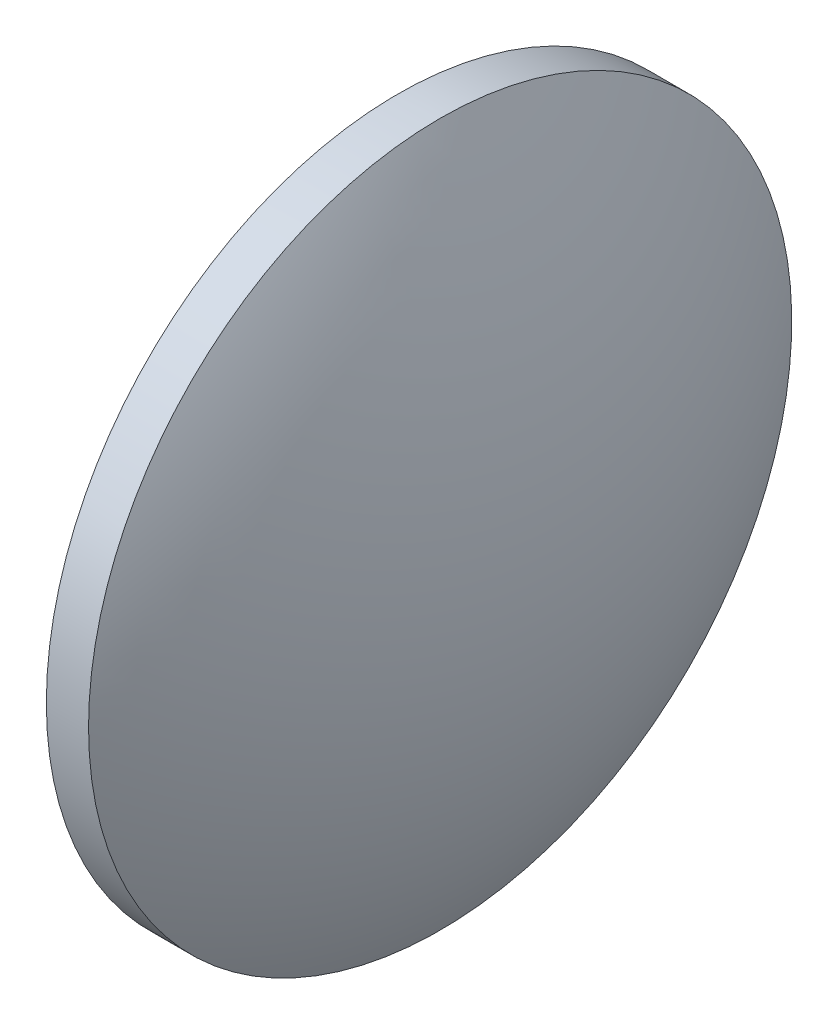
from build123d import *


with BuildPart() as part:
    # 草图1 → 旋转1 (revolve)
    with BuildSketch(Plane.XY):
        with BuildLine():
            Line((343.284470129, 9.632589186), (343.284470129, 34.632589186))
            Line((343.284470129, 34.632589186), (346.284470129, 34.632589186))
            ThreePointArc((346.284470129, 34.632589186), (351.095994088, 22.541912367), (352.734470129, 9.632589186))
            Line((352.734470129, 9.632589186), (343.284470129, 9.632589186))
        make_face()
    revolve(axis=Axis((339.31269484, 9.632589186, 0), (1, 0, 0)))


solid = part.part
